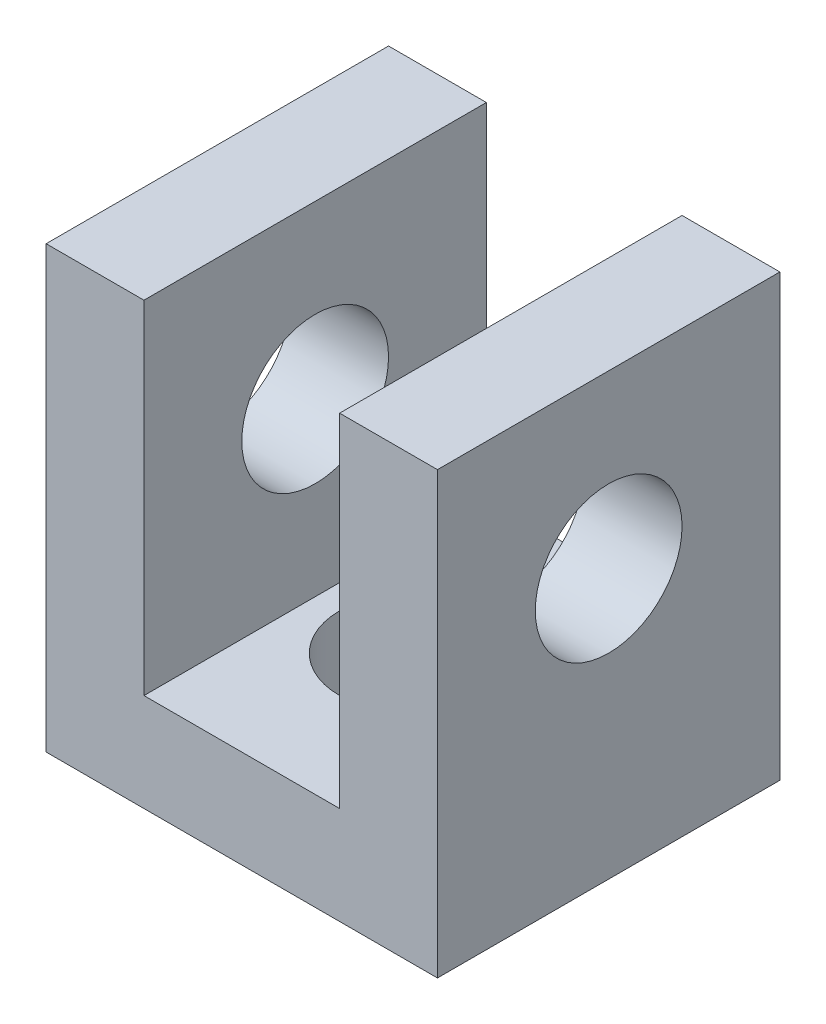
from build123d import *

# Parameters (mm, degrees)
BOSS_EXTRUDE1_DEPTH = 17.5
SKETCH2_R           = 7.5
CUT_EXTRUDE1_DEPTH  = 41
SKETCH3_R           = 7.5
CUT_EXTRUDE2_DEPTH  = 11


with BuildPart() as part:
    # Sketch1 → Boss-Extrude1 (new body, symmetric)
    with BuildSketch(Plane.XY):
        Polygon((-20, 45), (-20, 0), (20, 0), (20, 45), (10, 45), (10, 10), (-10, 10), (-10, 45), align=None)
    extrude(amount=BOSS_EXTRUDE1_DEPTH, both=True)

    # Sketch2 → Cut-Extrude1 (cut, through all)
    with BuildSketch(Plane(origin=(20, 0, 0), x_dir=(0, 0, -1), z_dir=(1, 0, 0))):
        with Locations((0, 27.5)):
            Circle(SKETCH2_R)
    extrude(amount=-CUT_EXTRUDE1_DEPTH, mode=Mode.SUBTRACT)

    # Sketch3 → Cut-Extrude2 (cut, through all)
    with BuildSketch(Plane(origin=(0, 10, 0), x_dir=(1, 0, 0), z_dir=(0, 1, 0))):
        Circle(SKETCH3_R)
    extrude(amount=-CUT_EXTRUDE2_DEPTH, mode=Mode.SUBTRACT)


solid = part.part
